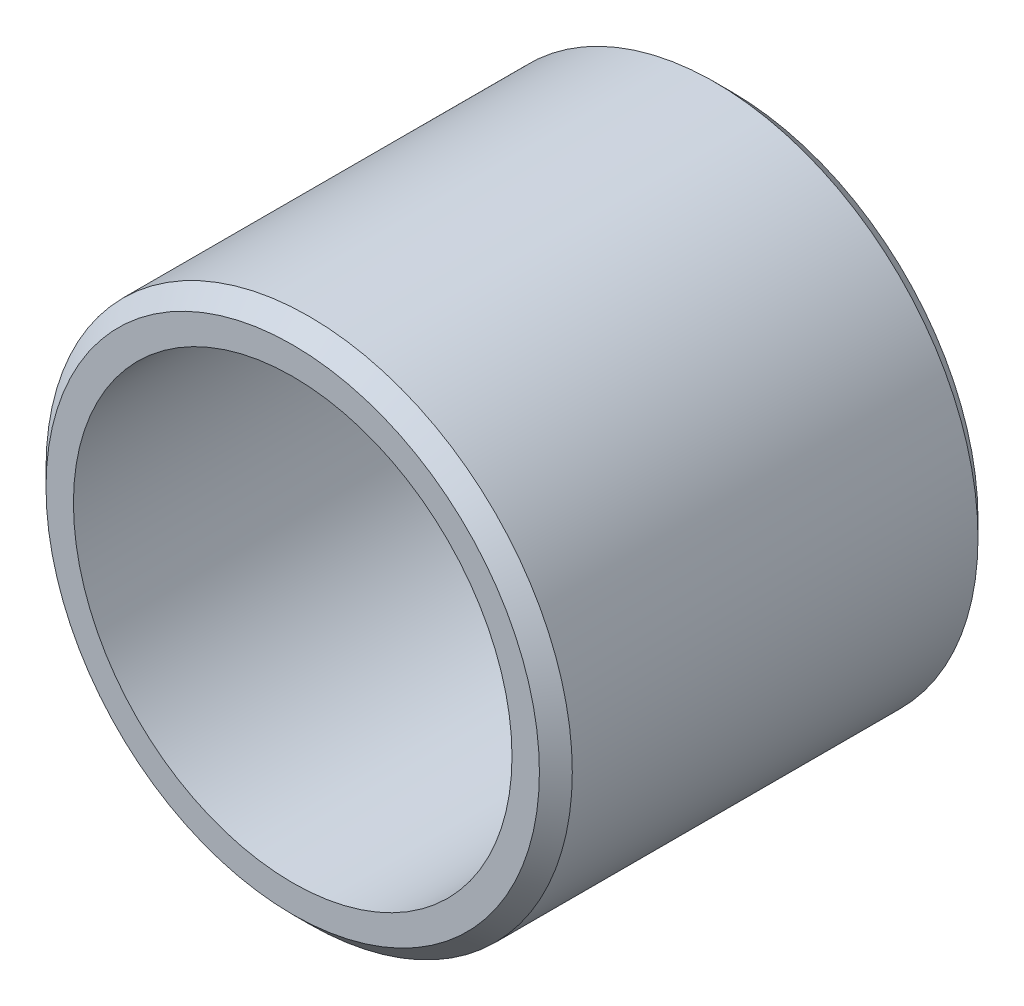
from build123d import *

# Parameters (mm, degrees)
SKETCH3_W     = 50
SKETCH3_H     = 5
CHAMFER1_SIZE = 1.875


with BuildPart() as part:
    # Sketch3 → Revolve1 (revolve)
    with BuildSketch(Plane(origin=(0, 0, 0), x_dir=(0, 0, -1), z_dir=(1, 0, 0))):
        with Locations((0, 27.5)):
            Rectangle(SKETCH3_W, SKETCH3_H)
    revolve(axis=Axis((0, 0, 25), (0, 0, -1)))

    # Chamfer1
    chamfer1_edges = [part.edges().sort_by_distance(p)[0] for p in [
        (0, -30, 25),
        (0, -30, -25),
    ]]
    chamfer(chamfer1_edges, length=CHAMFER1_SIZE)


solid = part.part
